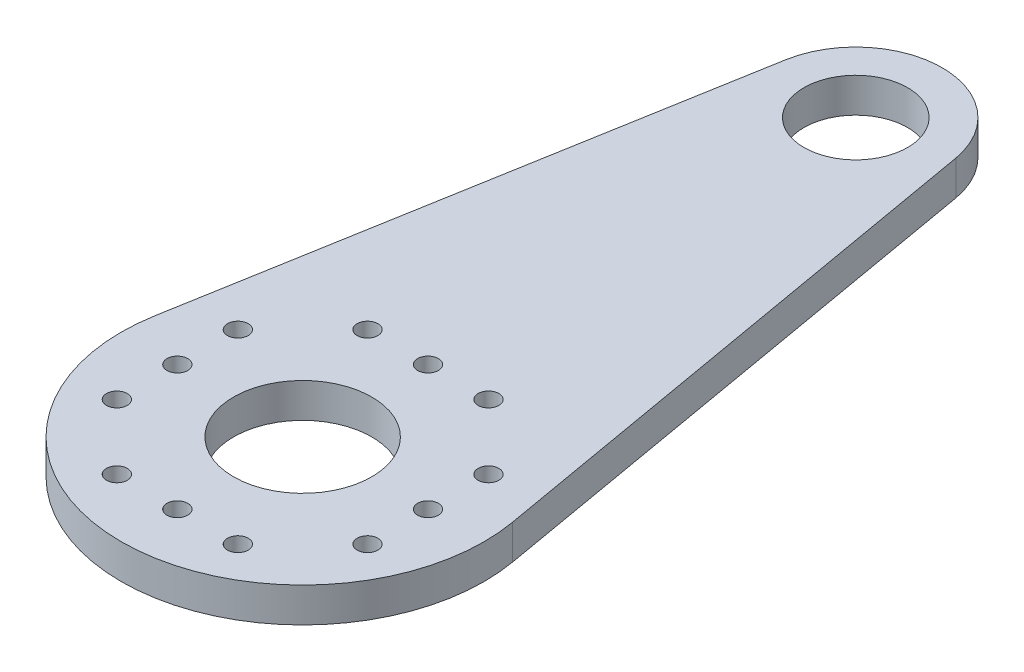
from build123d import *

# Parameters (mm, degrees)
CROQUIS1_R              = 4
CROQUIS1_R_2            = 3
SALIENTE_EXTRUIR1_DEPTH = 2
SKETCH1_R               = 0.6
CUT_EXTRUDE1_DEPTH      = 2
CIRPATTERN1_COUNT       = 4


with BuildPart() as part:
    # Croquis1 → Saliente-Extruir1 (new body)
    with BuildSketch(Plane(origin=(0, 0, 0), x_dir=(1, 0, 0), z_dir=(0, 1, 0))):
        with BuildLine():
            Line((4.925593833, 32.859375), (10.34374705, 1.8046875))
            ThreePointArc((10.34374705, 1.8046875), (0, -10.5), (-10.34374705, 1.8046875))
            Line((-10.34374705, 1.8046875), (-4.925593833, 32.859375))
            ThreePointArc((-4.925593833, 32.859375), (0, 37), (4.925593833, 32.859375))
        make_face()
        Circle(CROQUIS1_R, mode=Mode.SUBTRACT)
        with Locations((0, 32)):
            Circle(CROQUIS1_R_2, mode=Mode.SUBTRACT)
    extrude(amount=SALIENTE_EXTRUIR1_DEPTH)

    # Sketch1 → Cut-Extrude1 (cut)
    with BuildSketch(Plane(origin=(0, 2, 0), x_dir=(1, 0, 0), z_dir=(0, 1, 0))):
        with Locations((0, 7.25)):
            Circle(SKETCH1_R)
        with Locations((-3.5, 7.25)):
            Circle(SKETCH1_R)
        with Locations((3.5, 7.25)):
            Circle(SKETCH1_R)
    cut_extrude1 = extrude(amount=-CUT_EXTRUDE1_DEPTH, mode=Mode.SUBTRACT)

    # CirPattern1: Cut-Extrude1 ×4 about axis
    cirpattern1_axis = Axis((0, 0, 0), (0, 1, 0))
    for i in range(1, CIRPATTERN1_COUNT):
        add(cut_extrude1.rotate(cirpattern1_axis, i * 360 / CIRPATTERN1_COUNT), mode=Mode.SUBTRACT)


solid = part.part
